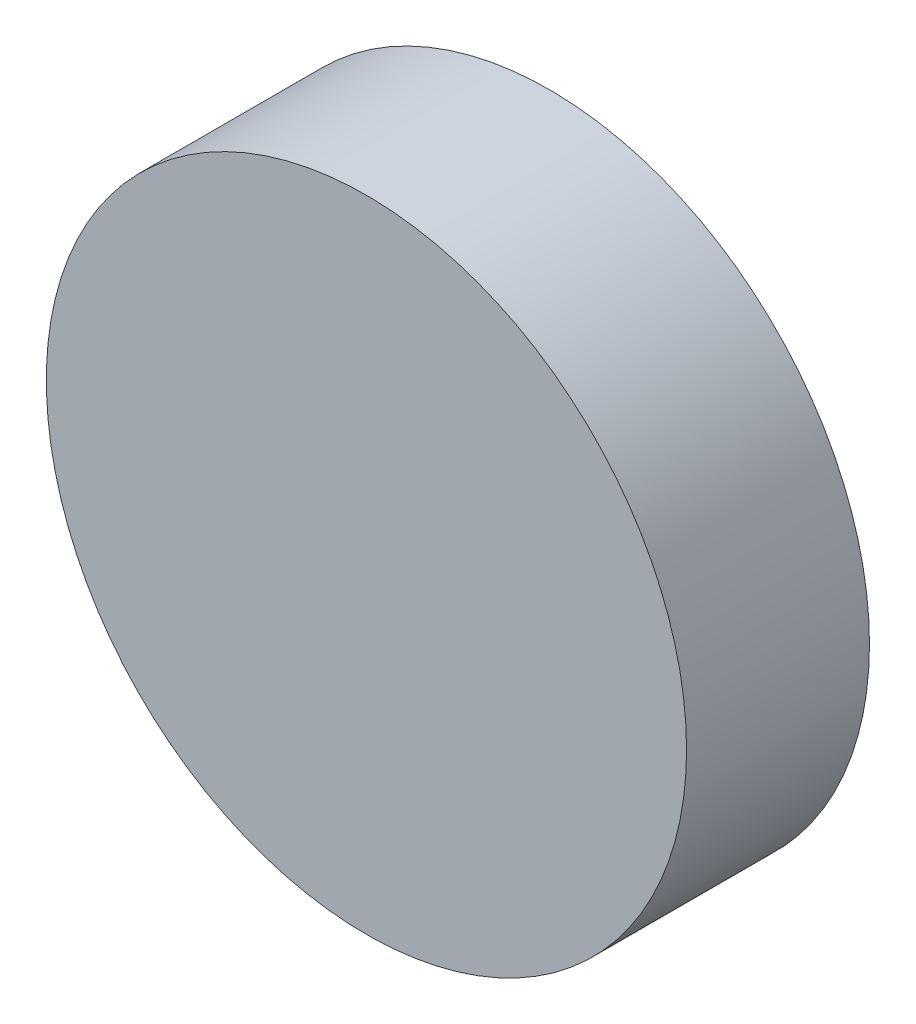
from build123d import *

# Parameters (mm, degrees)
SKETCH1_R           = 5.55625
BOSS_EXTRUDE1_DEPTH = 3.175


with BuildPart() as part:
    # Sketch1 → Boss-Extrude1 (new body)
    with BuildSketch(Plane.XY):
        Circle(SKETCH1_R)
    extrude(amount=BOSS_EXTRUDE1_DEPTH)


solid = part.part
